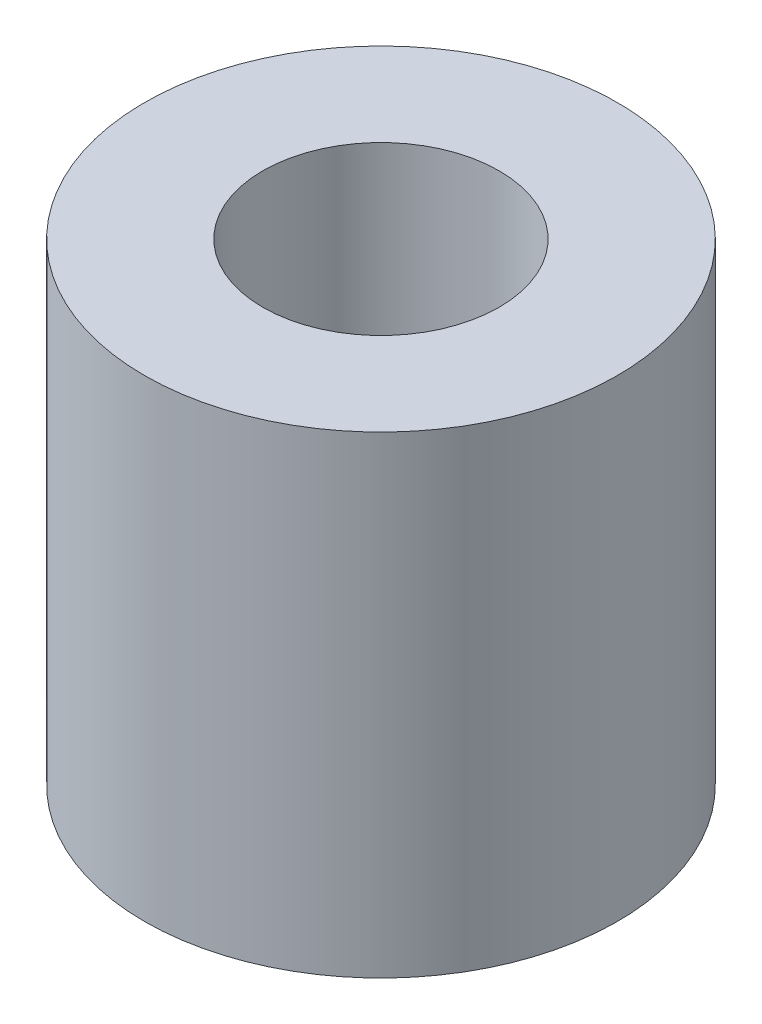
from build123d import *

# Parameters (mm, degrees)
SKETCH1_R           = 10
SKETCH1_R_2         = 3
BOSS_EXTRUDE1_DEPTH = 10
SKETCH2_R           = 10
SKETCH2_R_2         = 5
BOSS_EXTRUDE2_DEPTH = 10


with BuildPart() as part:
    # Sketch1 → Boss-Extrude1 (new body)
    with BuildSketch(Plane(origin=(0, 0, 0), x_dir=(1, 0, 0), z_dir=(0, 1, 0))):
        Circle(SKETCH1_R)
        Circle(SKETCH1_R_2, mode=Mode.SUBTRACT)
    extrude(amount=BOSS_EXTRUDE1_DEPTH)

    # Sketch2 → Boss-Extrude2 (add)
    with BuildSketch(Plane(origin=(0, 10, 0), x_dir=(1, 0, 0), z_dir=(0, 1, 0))):
        Circle(SKETCH2_R)
        Circle(SKETCH2_R_2, mode=Mode.SUBTRACT)
    extrude(amount=BOSS_EXTRUDE2_DEPTH)


solid = part.part
